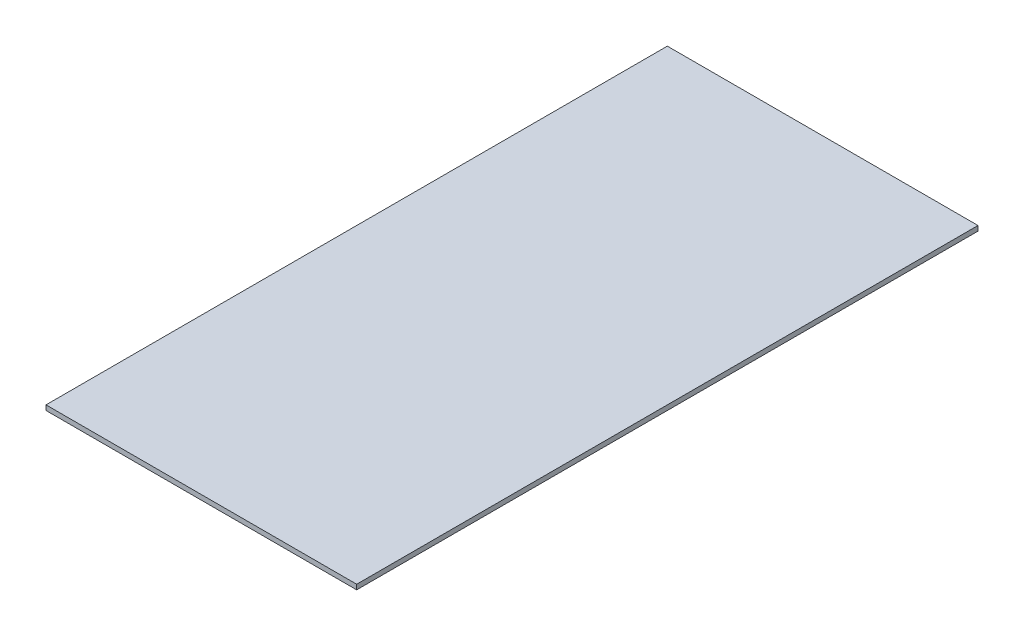
from build123d import *

# Parameters (mm, degrees)
SKETCH1_W          = 95
SKETCH1_H          = 190
BASE_EXTRUDE_DEPTH = 1.5


with BuildPart() as part:
    # Sketch1 → Base-Extrude (new body)
    with BuildSketch(Plane(origin=(0, 0, 0), x_dir=(1, 0, 0), z_dir=(0, 1, 0))):
        with Locations((0, 95)):
            Rectangle(SKETCH1_W, SKETCH1_H)
    extrude(amount=-BASE_EXTRUDE_DEPTH)


solid = part.part
